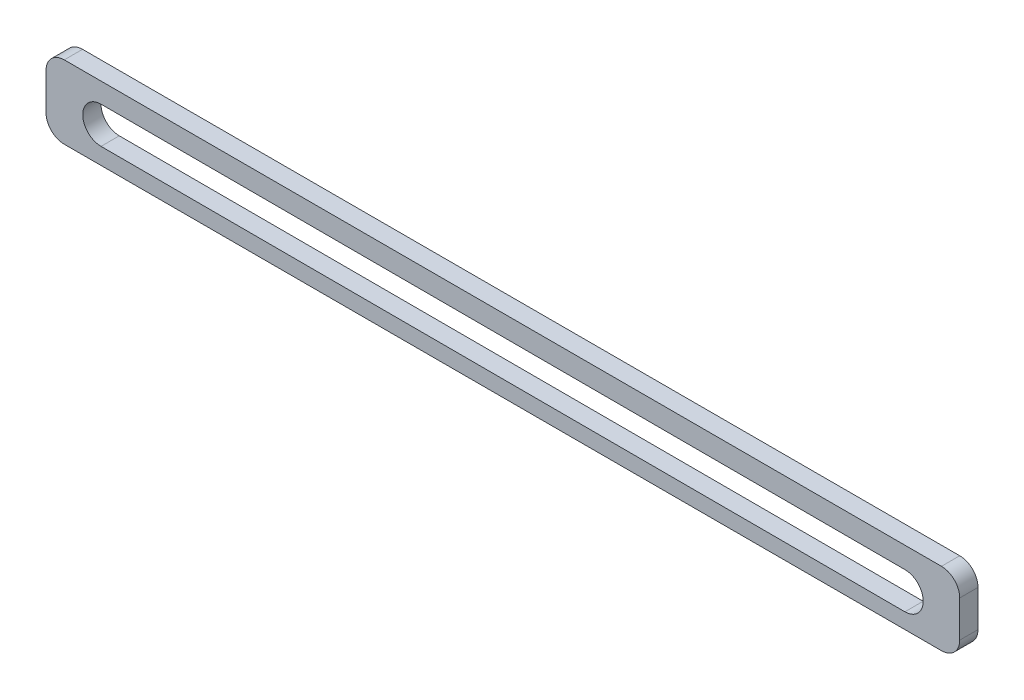
from build123d import *

# Parameters (mm, degrees)
BOSS_EXTRUDE1_DEPTH = 5


with BuildPart() as part:
    # Sketch1 → Boss-Extrude1 (new body, symmetric)
    with BuildSketch(Plane.XY):
        with BuildLine():
            Line((-190, 153.262074111), (290, 153.262074111))
            ThreePointArc((290, 153.262074111), (297.071067812, 150.333141922), (300, 143.262074111))
            Line((300, 143.262074111), (300, 123.262074111))
            ThreePointArc((300, 123.262074111), (297.071067812, 116.191006299), (290, 113.262074111))
            Line((290, 113.262074111), (-190, 113.262074111))
            ThreePointArc((-190, 113.262074111), (-197.071067812, 116.191006299), (-200, 123.262074111))
            Line((-200, 123.262074111), (-200, 143.262074111))
            ThreePointArc((-200, 143.262074111), (-197.071067812, 150.333141922), (-190, 153.262074111))
        make_face()
        with BuildLine():
            Line((-169.867316387, 142.322613738), (270.03251135, 141.702162641))
            ThreePointArc((270.03251135, 141.702162641), (280.018397045, 131.68806823), (270.004302633, 121.702182535))
            Line((270.004302633, 121.702182535), (-169.895525104, 122.322633632))
            ThreePointArc((-169.895525104, 122.322633632), (-179.881410799, 132.336728043), (-169.867316387, 142.322613738))
        make_face(mode=Mode.SUBTRACT)
    extrude(amount=BOSS_EXTRUDE1_DEPTH, both=True)


solid = part.part
